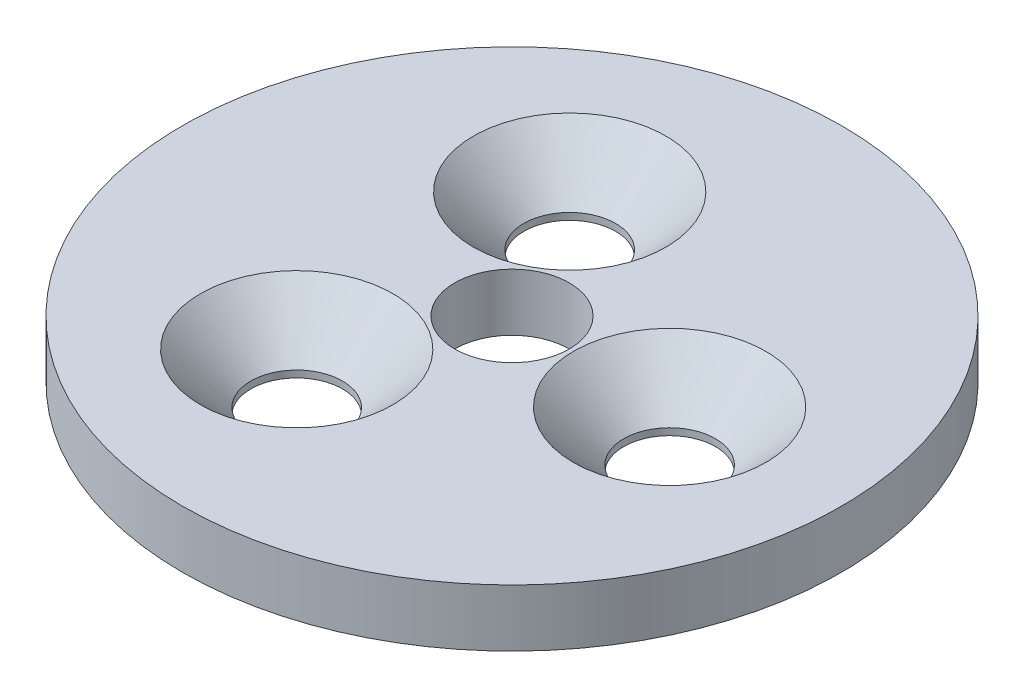
from build123d import *

# Parameters (mm, degrees)
SKIZZE1_R                          = 11.5
AUFSATZ_LINEAR_AUSTRAGEN1_DEPTH    = 2
KREISMUSTER1_COUNT                 = 3
F_4_0_4_DURCHMESSER_BOHRUNG1_D     = 4
F_4_0_4_DURCHMESSER_BOHRUNG1_DEPTH = 2


with BuildPart() as part:
    # Skizze1 → Aufsatz-Linear austragen1 (new body)
    with BuildSketch(Plane(origin=(0, 0, 0), x_dir=(1, 0, 0), z_dir=(0, 1, 0))):
        Circle(SKIZZE1_R)
    extrude(amount=AUFSATZ_LINEAR_AUSTRAGEN1_DEPTH)

    # Skizze2 → Formsenkung für M3 Senkschraube mit Innensechskant1 (revolve, cut)
    with BuildSketch(Plane(origin=(5.5, 2, 0), x_dir=(0, 0, 1), z_dir=(1, 0, 0))):
        Polygon((0, 0), (0, 2.001), (1.6, 2.001), (1.6, 1.76), (3.36, 0), align=None)
    formsenkung_f_r_m3_senkschraube_mit_inne = revolve(axis=Axis((5.5, 8.35, 0), (0, -1, 0)), mode=Mode.SUBTRACT)

    # Kreismuster1: Formsenkung für M3 Senkschraube mit Innensechskant1 ×3 about axis
    kreismuster1_axis = Axis((0, 0, 0), (0, 1, 0))
    for i in range(1, KREISMUSTER1_COUNT):
        add(formsenkung_f_r_m3_senkschraube_mit_inne.rotate(kreismuster1_axis, i * 360 / KREISMUSTER1_COUNT), mode=Mode.SUBTRACT)

    # Ø4.0 (4) Durchmesser Bohrung1
    with Locations(Plane(origin=(0, 2, 0), x_dir=(1, 0, 0), z_dir=(0, 1, 0))):
        with Locations((0, 0)):
            Hole(F_4_0_4_DURCHMESSER_BOHRUNG1_D / 2, depth=F_4_0_4_DURCHMESSER_BOHRUNG1_DEPTH)


solid = part.part
